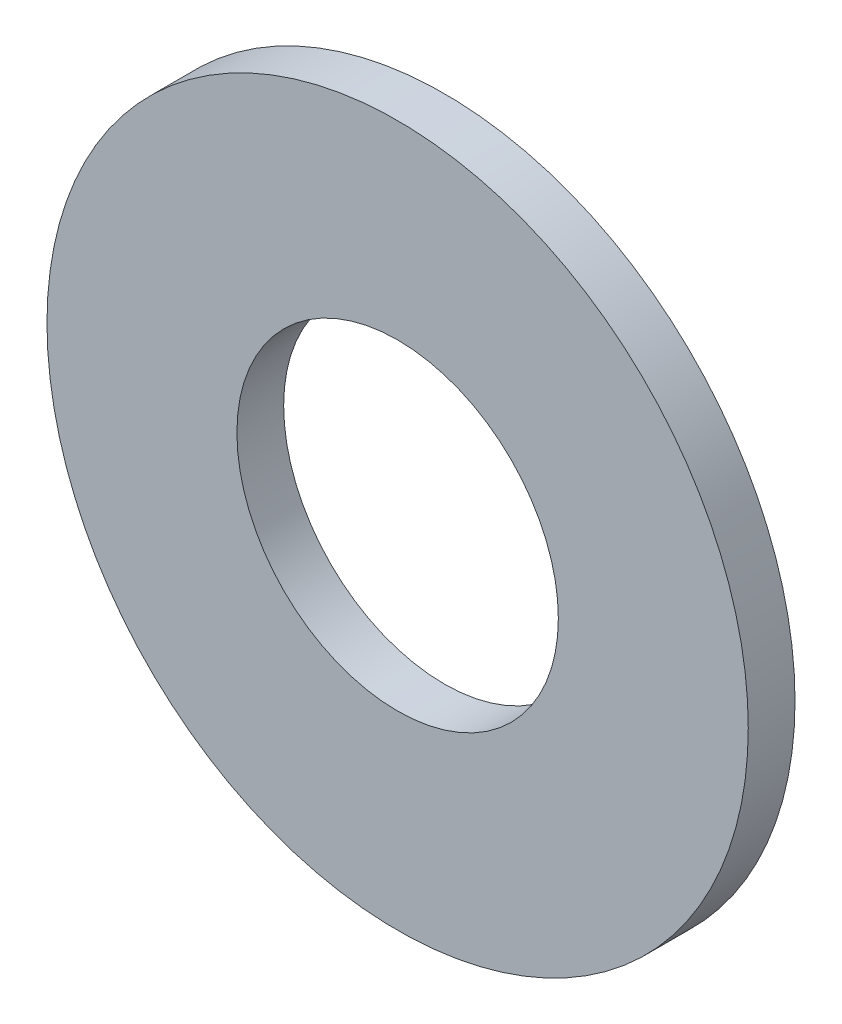
from build123d import *

# Parameters (mm, degrees)
SKETCH3_R           = 6
SKETCH3_R_2         = 2.75
BOSS_EXTRUDE1_DEPTH = 0.4


with BuildPart() as part:
    # Sketch3 → Boss-Extrude1 (new body, symmetric)
    with BuildSketch(Plane.XY):
        Circle(SKETCH3_R)
        Circle(SKETCH3_R_2, mode=Mode.SUBTRACT)
    extrude(amount=BOSS_EXTRUDE1_DEPTH, both=True)


solid = part.part
